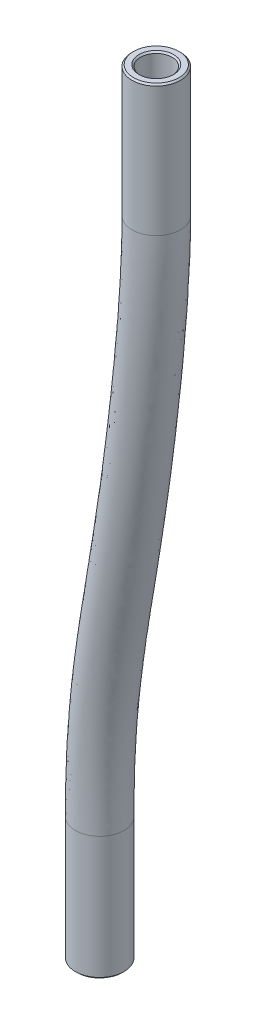
from build123d import *

# Parameters (mm, degrees)
SKETCH1_R     = 2
SKETCH1_R_2   = 1.3
CHAMFER1_SIZE = 0.127


with BuildPart() as part:
    # Sweep1: sweep along a curve in space
    with BuildLine() as sweep1_path:
        Line((-150.085279081, -93.282256564, 25.525), (-150.085279081, -103.482256564, 25.525))
        add(Edge.make_bspline(
            [(-143.943719565, -46.6, 27.001622999), (-143.943719565, -51.770788857, 27.001622999), (-147.014499323, -75.131743905, 26.263311499), (-150.085279081, -82.551529797, 25.525), (-150.085279081, -93.282256564, 25.525)],
            knots=[0, 0, 0, 0, 0.329296004, 1, 1, 1, 1], degree=3))
        Line((-143.943719565, -35.8, 27.001622999), (-143.943719565, -46.6, 27.001622999))
    # Sketch1 → Sweep1 (sweep)
    with BuildSketch(Plane(origin=(0, -95.382256564, 0), x_dir=(1, 0, 0), z_dir=(0, 1, 0))):
        with Locations((-150.085279081, -25.525)):
            Circle(SKETCH1_R)
        with Locations((-150.085279081, -25.525)):
            Circle(SKETCH1_R_2, mode=Mode.SUBTRACT)
    sweep(path=sweep1_path.line)

    # Chamfer1
    chamfer1_edges = [part.edges().sort_by_distance(p)[0] for p in [
        (-145.243719565, -35.8, 27.001622999),
        (-145.943719565, -35.8, 27.001622999),
        (-151.385279081, -103.482256564, 25.525),
        (-152.085279081, -103.482256564, 25.525),
    ]]
    chamfer(chamfer1_edges, length=CHAMFER1_SIZE)


solid = part.part
